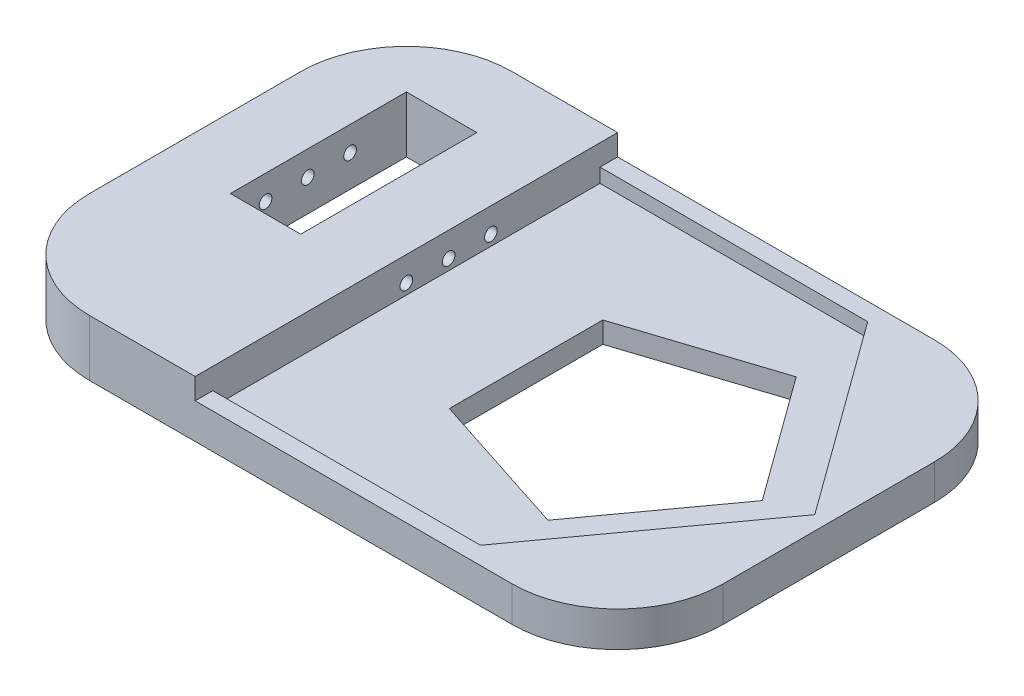
from build123d import *

# Parameters (mm, degrees)
SKETCH1_W           = 90
SKETCH1_H           = 60
BOSS_EXTRUDE1_DEPTH = 3
BOSS_EXTRUDE2_DEPTH = 2
SKETCH4_W           = 30
SKETCH4_H           = 60
BOSS_EXTRUDE4_DEPTH = 3
SKETCH5_R           = 0.9
CUT_EXTRUDE1_DEPTH  = 22
SKETCH6_W           = 10
SKETCH6_H           = 25
CUT_EXTRUDE2_DEPTH  = 9
FILLET1_R           = 15
CUT_EXTRUDE3_DEPTH  = 4


with BuildPart() as part:
    # Sketch1 → Boss-Extrude1 (new body)
    with BuildSketch(Plane(origin=(0, 0, 0), x_dir=(1, 0, 0), z_dir=(0, 1, 0))):
        Rectangle(SKETCH1_W, SKETCH1_H)
    extrude(amount=-BOSS_EXTRUDE1_DEPTH)

    # Sketch2 → Boss-Extrude2 (add)
    with BuildSketch(Plane(origin=(0, 0, 0), x_dir=(1, 0, 0), z_dir=(0, 1, 0))):
        Polygon((45, 30), (-45, 30), (-45, 27.5), (-45, -27.5), (-45, -30), (45, -30), align=None)
        Polygon((43, 0), (23.02008048, 27.5), (-15, 27.5), (-15, -27.5), (23.02008048, -27.5), align=None, mode=Mode.SUBTRACT)
    extrude(amount=BOSS_EXTRUDE2_DEPTH)

    # Sketch4 → Boss-Extrude4 (add)
    with BuildSketch(Plane(origin=(0, 2, 0), x_dir=(1, 0, 0), z_dir=(0, 1, 0))):
        with Locations((-30, 0)):
            Rectangle(SKETCH4_W, SKETCH4_H)
    extrude(amount=BOSS_EXTRUDE4_DEPTH)

    # Sketch5 → Cut-Extrude1 (cut)
    with BuildSketch(Plane(origin=(-15, 0, 0), x_dir=(0, 0, -1), z_dir=(1, 0, 0))):
        with Locations((0, 1.5)):
            Circle(SKETCH5_R)
        with Locations((6, 1.5)):
            Circle(SKETCH5_R)
        with Locations((12, 1.5)):
            Circle(SKETCH5_R)
    extrude(amount=-CUT_EXTRUDE1_DEPTH, mode=Mode.SUBTRACT)

    # Sketch6 → Cut-Extrude2 (cut, through all)
    with BuildSketch(Plane(origin=(0, 5, 0), x_dir=(1, 0, 0), z_dir=(0, 1, 0))):
        with Locations((-30, 7.5)):
            Rectangle(SKETCH6_W, SKETCH6_H)
    extrude(amount=-CUT_EXTRUDE2_DEPTH, mode=Mode.SUBTRACT)

    # Fillet1
    fillet1_edges = [part.edges().sort_by_distance(p)[0] for p in [
        (-45, 1, -30),
        (-45, 1, 30),
        (45, -0.5, 30),
        (45, -0.5, -30),
    ]]
    fillet(fillet1_edges, radius=FILLET1_R)

    # Sketch7 → Cut-Extrude3 (cut, through all)
    with BuildSketch(Plane(origin=(0, 0, 0), x_dir=(1, 0, 0), z_dir=(0, 1, 0))):
        Polygon((35.541019662, 0), (22.729490169, 17.633557569), (2, 10.89813792), (2, -10.89813792), (22.729490169, -17.633557569), align=None)
    extrude(amount=-CUT_EXTRUDE3_DEPTH, mode=Mode.SUBTRACT)


solid = part.part
